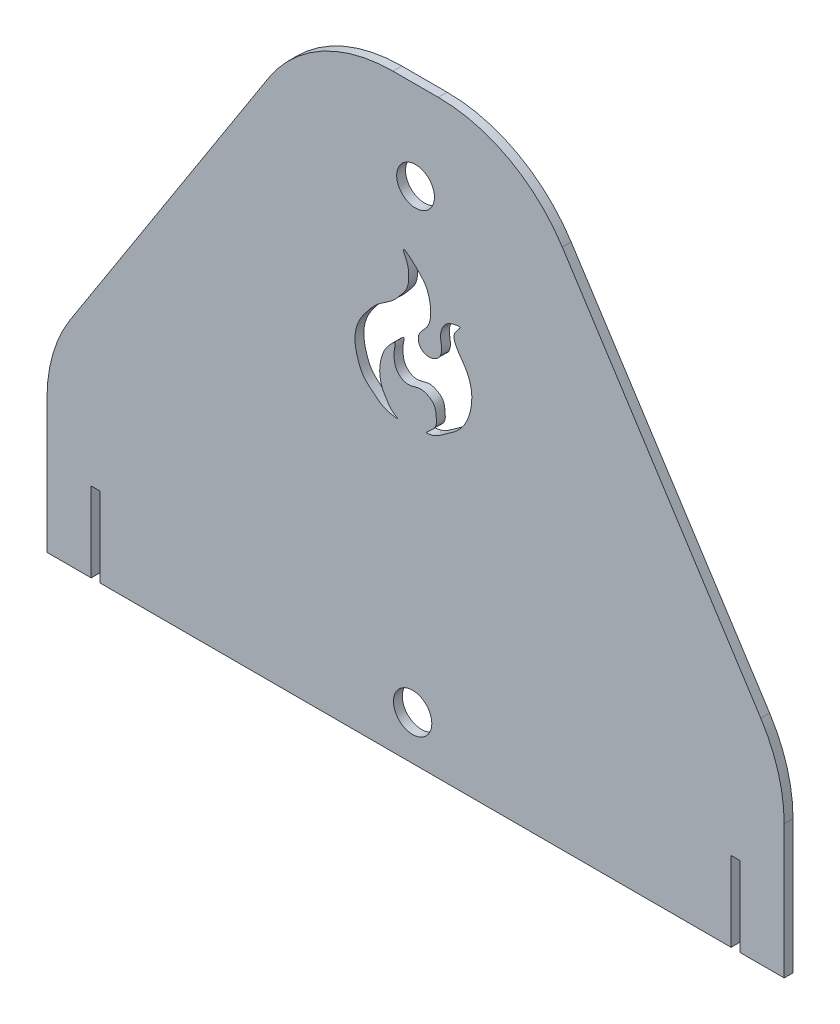
from build123d import *

# Parameters (mm, degrees)
CROQUIS1_R              = 6.4
SALIENTE_EXTRUIR1_DEPTH = 3
REDONDEO1_R             = 50
CROQUIS3_W              = 3
CROQUIS3_H              = 27
CORTAR_EXTRUIR2_DEPTH   = 4
CORTAR_EXTRUIR3_DEPTH   = 4
CROQUIS5_R              = 6.5
CORTAR_EXTRUIR4_DEPTH   = 4.0000001


with BuildPart() as part:
    # Croquis1 → Saliente-Extruir1 (new body)
    with BuildSketch(Plane.XY):
        Polygon((-35, 100), (-125, -40), (-125, -100), (125, -100), (125, -40), (35, 100), align=None)
        with Locations((0, 70)):
            Circle(CROQUIS1_R, mode=Mode.SUBTRACT)
    extrude(amount=SALIENTE_EXTRUIR1_DEPTH)

    # Redondeo1
    redondeo1_edges = [part.edges().sort_by_distance(p)[0] for p in [
        (125, -40, 1.5),
        (-125, -40, 1.5),
        (-35, 100, 1.5),
        (35, 100, 1.5),
    ]]
    fillet(redondeo1_edges, radius=REDONDEO1_R)

    # Croquis3 → Cortar-Extruir2 (cut, through all)
    with BuildSketch(Plane.XY.offset(3)):
        with Locations((-108.5, -86.5)):
            Rectangle(CROQUIS3_W, CROQUIS3_H)
        with Locations((108.5, -86.5)):
            Rectangle(CROQUIS3_W, CROQUIS3_H)
    extrude(amount=-CORTAR_EXTRUIR2_DEPTH, mode=Mode.SUBTRACT)

    # Croquis4 → Cortar-Extruir3 (cut, through all)
    with BuildSketch(Plane.XY.offset(3)):
        with BuildLine():
            add(Edge.make_bspline(
                [(-4.127253397, 49.095948447), (-4.518292422, 50.628629877), (2.396503163, 44.625470017), (4.49982381, 40.934602708), (5.51587752, 35.089987557), (4.299085831, 30.411026251), (1.445516869, 28.299054936), (0.645683902, 25.557437121), (1.565485094, 23.214865097), (3.758804694, 21.990766891), (6.296397176, 22.298493218), (8.801838277, 24.134275281), (8.902772506, 27.536135631), (8.124262832, 30.821898129), (9.545735234, 34.40846044), (11.869248673, 35.79962002), (15.955296863, 36.623138378), (13.669744064, 34.350652159), (12.656381341, 32.452368444), (14.051234415, 28.836755045), (17.083583234, 25.404522589), (19.294902733, 19.898235269), (18.997713777, 13.821917493), (17.049499088, 8.367308911), (13.429778298, 4.398536509), (9.504483896, 2.094988905), (7.139680817, -0.020721519), (2.016397505, -1.092169029), (7.306665897, 2.108713194), (7.008367313, 5.538028199), (6.795703447, 8.951326958), (4.253781924, 10.798049353), (1.547265791, 11.684173396), (-0.700008666, 10.753155662), (-2.729207964, 10.503659493), (-4.495454133, 10.918775765), (-5.978317825, 12.150738013), (-7.0190985, 13.841218795), (-7.157525826, 15.168981138), (-7.354780322, 16.462611202), (-7.329266822, 18.264249326), (-6.446985191, 21.601267517), (-10.061748352, 17.813447907), (-11.192358925, 15.399218411), (-12.170908614, 11.732035035), (-12.221073205, 8.326859506), (-11.471705322, 5.03118445), (-9.583423776, 2.270724422), (-8.524361737, 0.199461894), (-4.854316134, -1.700599076), (-10.896829519, -0.637239765), (-13.554766663, 1.678008095), (-17.999543497, 5.07857505), (-19.843056188, 10.00234362), (-21.014365257, 15.324992136), (-19.557119388, 21.062642314), (-16.13898935, 25.537302932), (-12.549293298, 29.676860603), (-8.016815009, 31.958950418), (-5.105038333, 35.472033491), (-2.465383815, 38.661236487), (-2.22360169, 42.783180885), (-2.561547925, 46.023501571), (-3.98707795, 48.546529359), (-4.127253397, 49.095948447)],
                knots=[0, 0, 0, 0, 0.031004368, 0.060687118, 0.089933035, 0.112422621, 0.130059187, 0.140777644, 0.153021948, 0.164925723, 0.175677485, 0.190180761, 0.207268194, 0.222520436, 0.241753772, 0.257857382, 0.269984325, 0.279656599, 0.290001634, 0.304322992, 0.331994342, 0.360844346, 0.390196021, 0.421995478, 0.445705213, 0.470225433, 0.487264531, 0.500608193, 0.520142789, 0.535921191, 0.554344335, 0.567339408, 0.580570773, 0.595399094, 0.602337895, 0.611213429, 0.621780718, 0.630602379, 0.640133217, 0.642295972, 0.652229924, 0.659039006, 0.669931674, 0.686356922, 0.698408895, 0.71063926, 0.725152457, 0.735995301, 0.747275569, 0.754938292, 0.766749173, 0.785852906, 0.807015742, 0.824714385, 0.844773845, 0.86805795, 0.888839966, 0.908343416, 0.929635387, 0.94491421, 0.959922629, 0.975412629, 0.988885889, 1, 1, 1, 1], degree=3))
        make_face()
    extrude(amount=-CORTAR_EXTRUIR3_DEPTH, mode=Mode.SUBTRACT)

    # Croquis5 → Cortar-Extruir4 (cut, through all)
    with BuildSketch(Plane.XY.offset(3)):
        with Locations((-1, -85)):
            Circle(CROQUIS5_R)
    extrude(amount=-CORTAR_EXTRUIR4_DEPTH, mode=Mode.SUBTRACT)


solid = part.part
